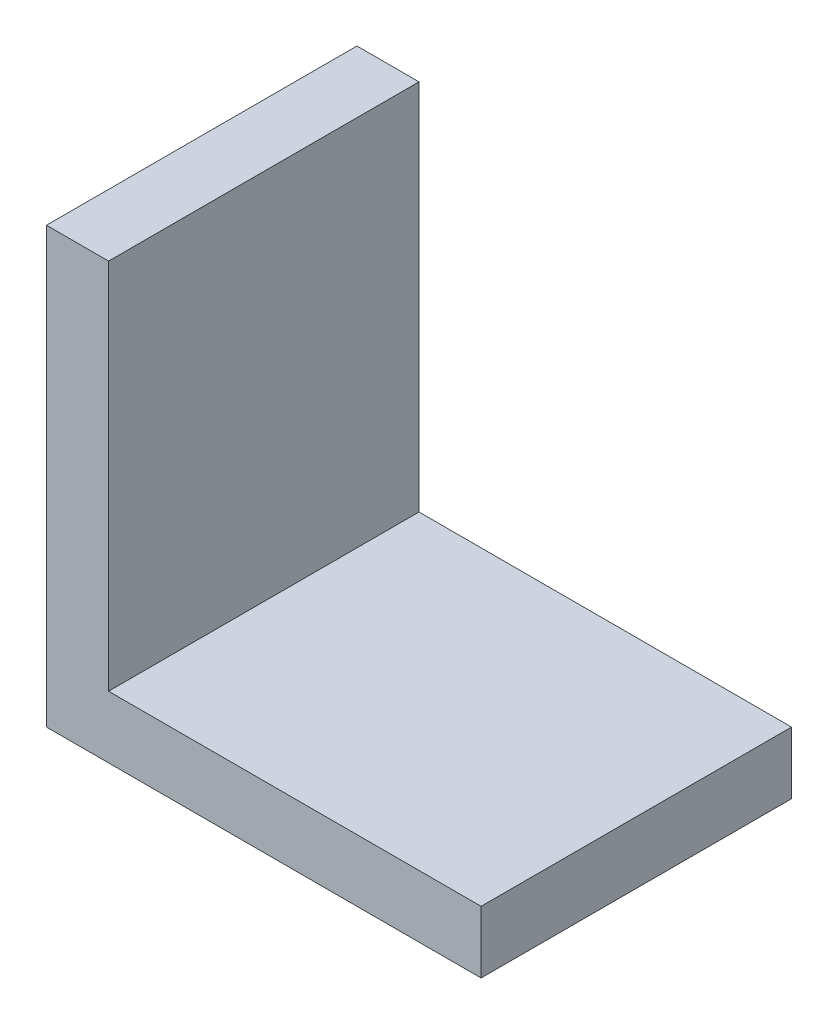
from build123d import *

# Parameters (mm, degrees)
BOSS_EXTRUDE1_DEPTH = 20
SKETCH5_R           = 2.5
BOSS_EXTRUDE6_DEPTH = 6.4
SKETCH6_R           = 2.5
BOSS_EXTRUDE7_DEPTH = 6.4


with BuildPart() as part:
    # Sketch1 → Boss-Extrude1 (new body)
    with BuildSketch(Plane.XY):
        Polygon((0, 0), (0, 28), (4, 28), (4, 4), (28, 4), (28, 0), align=None)
    extrude(amount=BOSS_EXTRUDE1_DEPTH)

    # Sketch5 → Boss-Extrude6 (add)
    with BuildSketch(Plane.ZY):
        with Locations((10, 14)):
            Circle(SKETCH5_R)
    extrude(amount=BOSS_EXTRUDE6_DEPTH)

    # Sketch6 → Boss-Extrude7 (add)
    with BuildSketch(Plane.XZ):
        with Locations((14, 10)):
            Circle(SKETCH6_R)
    extrude(amount=BOSS_EXTRUDE7_DEPTH)


solid = part.part
